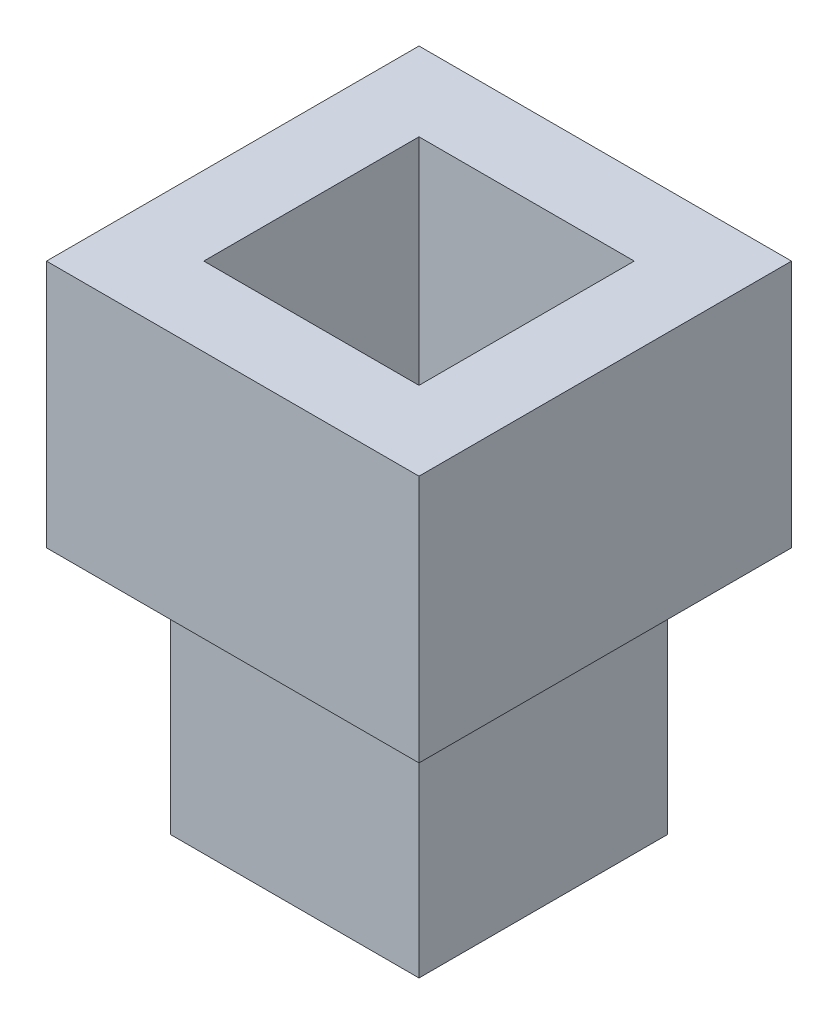
from build123d import *

# Parameters (mm, degrees)
SKETCH1_W           = 30
SKETCH1_H           = 30
BOSS_EXTRUDE1_DEPTH = 30
SKETCH2_W           = 45
SKETCH2_H           = 45
BOSS_EXTRUDE2_DEPTH = 10
SKETCH4_W           = 45
SKETCH4_H           = 45
BOSS_EXTRUDE3_DEPTH = 20
SKETCH5_R           = 9.5
CUT_EXTRUDE1_DEPTH  = 40
SKETCH6_W           = 26
SKETCH6_H           = 26
CUT_EXTRUDE2_DEPTH  = 30
SKETCH7_R           = 2.5
CUT_EXTRUDE3_DEPTH  = 20


with BuildPart() as part:
    # Sketch1 → Boss-Extrude1 (new body)
    with BuildSketch(Plane(origin=(0, 0, 0), x_dir=(1, 0, 0), z_dir=(0, 1, 0))):
        with Locations((15, 15)):
            Rectangle(SKETCH1_W, SKETCH1_H)
    extrude(amount=BOSS_EXTRUDE1_DEPTH)

    # Sketch2 → Boss-Extrude2 (add)
    with BuildSketch(Plane(origin=(0, 30, 0), x_dir=(1, 0, 0), z_dir=(0, 1, 0))):
        with Locations((15, 15)):
            Rectangle(SKETCH2_W, SKETCH2_H)
    extrude(amount=BOSS_EXTRUDE2_DEPTH)

    # Sketch4 → Boss-Extrude3 (add)
    with BuildSketch(Plane(origin=(0, 40, 0), x_dir=(1, 0, 0), z_dir=(0, 1, 0))):
        with Locations((15, 15)):
            Rectangle(SKETCH4_W, SKETCH4_H)
    extrude(amount=BOSS_EXTRUDE3_DEPTH)

    # Sketch5 → Cut-Extrude1 (cut)
    with BuildSketch(Plane(origin=(0, 60, 0), x_dir=(1, 0, 0), z_dir=(0, 1, 0))):
        with Locations((15, 15)):
            Circle(SKETCH5_R)
    extrude(amount=-CUT_EXTRUDE1_DEPTH, mode=Mode.SUBTRACT)

    # Sketch6 → Cut-Extrude2 (cut)
    with BuildSketch(Plane(origin=(0, 60, 0), x_dir=(1, 0, 0), z_dir=(0, 1, 0))):
        with Locations((15, 15)):
            Rectangle(SKETCH6_W, SKETCH6_H)
    extrude(amount=-CUT_EXTRUDE2_DEPTH, mode=Mode.SUBTRACT)

    # Sketch7 → Cut-Extrude3 (cut)
    with BuildSketch(Plane.XZ):
        with Locations((25, -25)):
            Circle(SKETCH7_R)
        with Locations((5, -25)):
            Circle(SKETCH7_R)
        with Locations((5, -5)):
            Circle(SKETCH7_R)
        with Locations((25, -5)):
            Circle(SKETCH7_R)
    extrude(amount=-CUT_EXTRUDE3_DEPTH, mode=Mode.SUBTRACT)


solid = part.part
